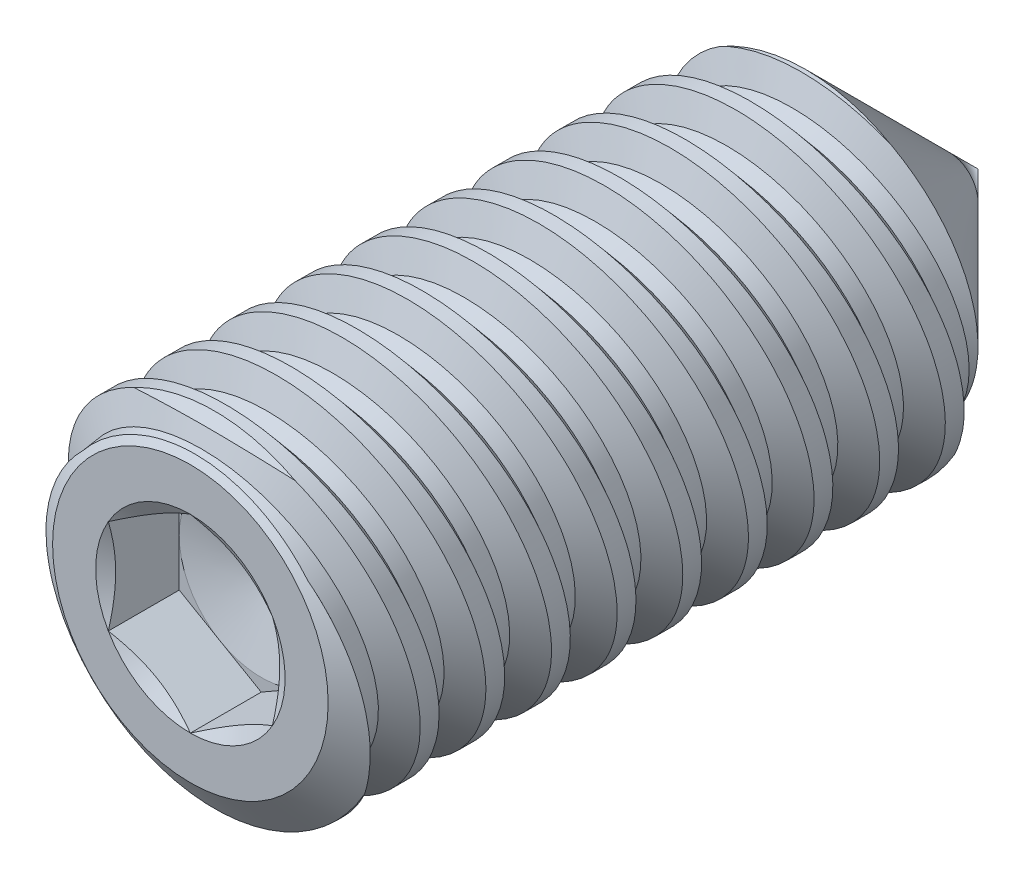
from build123d import *

# Parameters (mm, degrees)
LPATTERN1_COUNT      = 10
LPATTERN1_PITCH      = 0.79375
LPATTERN1_COUNT_DIR2 = 2
LPATTERN1_PITCH_DIR2 = 0.79375
CUT_EXTRUDE10_DEPTH  = 0.85725


with BuildPart() as part:
    # Sketch22 → Revolve1 (revolve)
    with BuildSketch(Plane(origin=(0, 0, 0), x_dir=(0, 0, -1), z_dir=(1, 0, 0))):
        Polygon((-4.7625, 0), (-4.7625, 1.66624), (-4.470821548, 2.0828), (2.6797, 2.0828), (4.7625, 0), align=None)
    revolve(axis=Axis((0, 0, -5.271025863), (0, 0, 1)))

    # Sketch6 → Cut-Revolve8 (revolve, cut)
    with BuildSketch(Plane(origin=(0, 0, 0), x_dir=(0, 0, -1), z_dir=(1, 0, 0))):
        Polygon((2.516455739, 1.762908932), (2.321525531, 1.725765218), (1.997444272, 2.101371857), (2.6797, 2.231374854), align=None)
    cut_revolve8 = revolve(axis=Axis((0, 0.162231854, -3.602764706), (0, -0.18718091792156344, 0.9823254572523513)), mode=Mode.SUBTRACT)

    # LPattern1: Cut-Revolve8 10 × 2
    with Locations(*[Vector(0, 0, 1) * (i * LPATTERN1_PITCH) + Vector(0, 0, -1) * (j * LPATTERN1_PITCH_DIR2) for i in range(LPATTERN1_COUNT) for j in range(LPATTERN1_COUNT_DIR2) if (i, j) != (0, 0)]):
        add(cut_revolve8, mode=Mode.SUBTRACT)

    # Sketch23 → Cut-Extrude10 (cut)
    with BuildSketch(Plane.XY.offset(4.7625)):
        Polygon((0, 1.14567944), (-0.9921875, 0.57283972), (-0.9921875, -0.57283972), (0, -1.14567944), (0.9921875, -0.57283972), (0.9921875, 0.57283972), align=None)
    extrude(amount=-CUT_EXTRUDE10_DEPTH, mode=Mode.SUBTRACT)

    # Cut-Extrude11 cone 1 section (through the dimple's axis) → Cut-Extrude11 (revolve, cut)
    with BuildSketch(Plane(origin=(0, 0, 4.7625), x_dir=(0, -1, 0), z_dir=(1, 0, 0))):
        Polygon((0, 0), (1.14567944, 0), (0, 0.661458333), align=None)
    revolve(axis=Axis((0, 0, 4.7625), (0, 0, -1)), mode=Mode.SUBTRACT)

    # Cut-Extrude12 cone 1 section (through the dimple's axis) → Cut-Extrude12 (revolve, cut)
    with BuildSketch(Plane(origin=(0, 0, 3.90525), x_dir=(0, -1, 0), z_dir=(1, 0, 0))):
        Polygon((0, 0), (0.9921875, 0), (0, 0.265855839), align=None)
    revolve(axis=Axis((0, 0, 3.90525), (0, 0, -1)), mode=Mode.SUBTRACT)


solid = part.part
